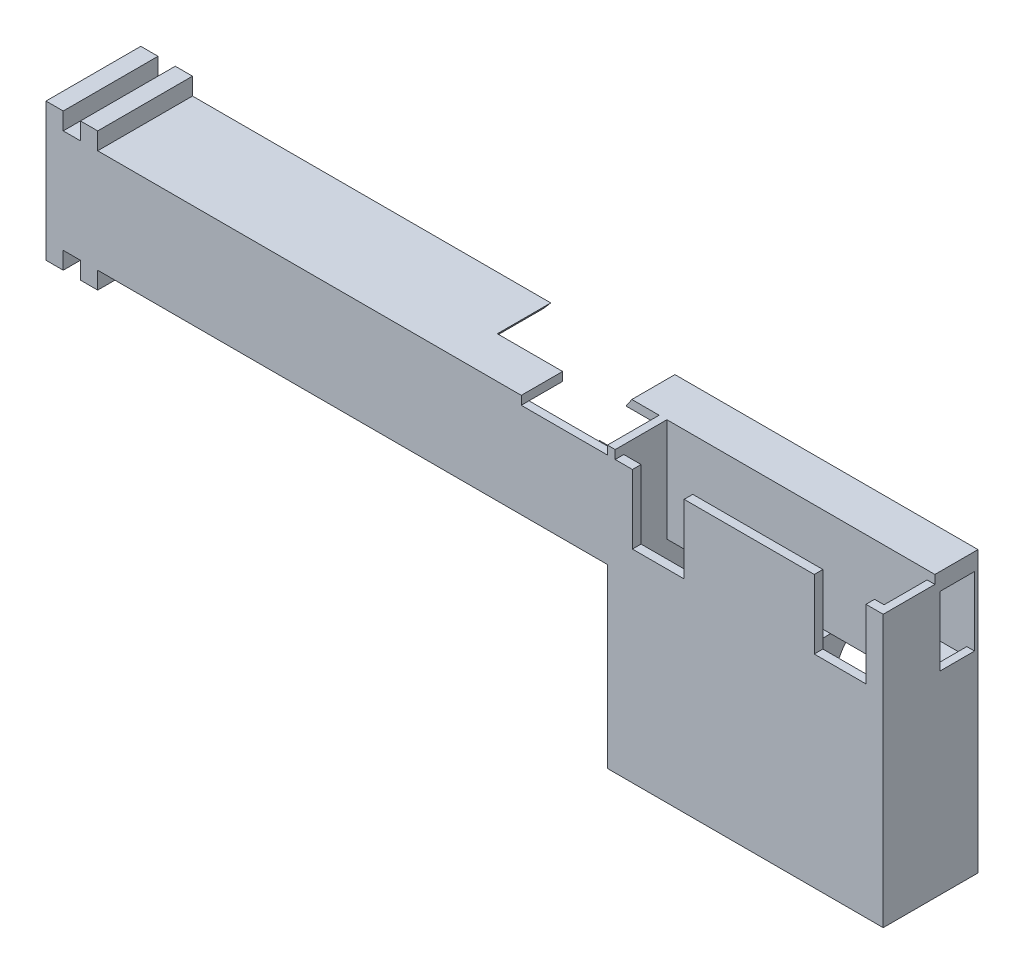
from build123d import *

# Parameters (mm, degrees)
BOSS_EXTRUDE2_DEPTH  = 11
BOSS_EXTRUDE3_DEPTH  = 5
SKETCH2_W            = 30.2
SKETCH2_H            = 1
BOSS_EXTRUDE4_DEPTH  = 25.5
SKETCH1_W            = 7.8
SKETCH1_H            = 14.5
BOSS_EXTRUDE5_DEPTH  = 11
SKETCH3_W            = 11.2
SKETCH3_H            = 11
BOSS_EXTRUDE6_DEPTH  = 5
SKETCH4_W            = 31.1
SKETCH4_H            = 4
CUT_EXTRUDE1_DEPTH   = 10
SKETCH5_W            = 32
SKETCH5_H            = 5
BOSS_EXTRUDE7_DEPTH  = 1
SKETCH7_W            = 5
SKETCH7_H            = 1
SKETCH7_H_2          = 1.003816478
BOSS_EXTRUDE8_DEPTH  = 62.24
SKETCH8_W            = 0.9
SKETCH8_H            = 1
BOSS_EXTRUDE9_DEPTH  = 6
BOSS_EXTRUDE10_DEPTH = 62.26
SKETCH10_W           = 52.24
SKETCH10_H           = 1
BOSS_EXTRUDE11_DEPTH = 6
SKETCH11_R           = 81.7
SKETCH11_R_2         = 70.15
CUT_EXTRUDE2_DEPTH   = 6.2
BOSS_EXTRUDE12_DEPTH = 2.91
SKETCH14_W           = 2
SKETCH14_H           = 11
BOSS_EXTRUDE13_DEPTH = 2
SKETCH15_W           = 2
SKETCH15_H           = 11
BOSS_EXTRUDE14_DEPTH = 2
SKETCH20_RX          = 7.25
SKETCH20_RY          = 5
CUT_EXTRUDE3_DEPTH   = 10
SKETCH21_W           = 6
SKETCH21_H           = 8
CUT_EXTRUDE4_DEPTH   = 1
SKETCH22_W           = 4
SKETCH22_H           = 8
CUT_EXTRUDE5_DEPTH   = 1


with BuildPart() as part:
    # Sketch1_3 → Boss-Extrude2 (new body)
    with BuildSketch(Plane.XY):
        Polygon((0, 31.5), (0, 0), (32, 0), (32, 31.5), (31.1, 31.5), (31.1, 6), (0.9, 6), (0.9, 31.5), align=None)
    extrude(amount=BOSS_EXTRUDE2_DEPTH)

    # Sketch1_4 → Boss-Extrude3 (add)
    with BuildSketch(Plane.XY):
        Polygon((0.9, 31.5), (0.9, 20.5), (12.1, 20.5), (19.9, 20.5), (31.1, 20.5), (31.1, 31.5), align=None)
    extrude(amount=BOSS_EXTRUDE3_DEPTH)

    # Sketch2 → Boss-Extrude4 (add)
    with BuildSketch(Plane(origin=(0, 6, 0), x_dir=(1, 0, 0), z_dir=(0, 1, 0))):
        with Locations((16, -10.5)):
            Rectangle(SKETCH2_W, SKETCH2_H)
    extrude(amount=BOSS_EXTRUDE4_DEPTH)

    # Sketch1 → Boss-Extrude5 (add)
    with BuildSketch(Plane.XY):
        with Locations((16, 13.25)):
            Rectangle(SKETCH1_W, SKETCH1_H)
    extrude(amount=BOSS_EXTRUDE5_DEPTH)

    # Sketch3 → Boss-Extrude6 (add)
    with BuildSketch(Plane(origin=(0, 0, 10), x_dir=(-1, 0, 0), z_dir=(0, 0, -1))):
        with Locations((-6.5, 11.5)):
            Rectangle(SKETCH3_W, SKETCH3_H)
        with Locations((-25.5, 11.5)):
            Rectangle(SKETCH3_W, SKETCH3_H)
    extrude(amount=BOSS_EXTRUDE6_DEPTH)

    # Sketch4 → Cut-Extrude1 (cut)
    with BuildSketch(Plane(origin=(0, 31.5, 0), x_dir=(1, 0, 0), z_dir=(0, 1, 0))):
        with Locations((15.55, -2.4)):
            Rectangle(SKETCH4_W, SKETCH4_H)
    extrude(amount=-CUT_EXTRUDE1_DEPTH, mode=Mode.SUBTRACT)

    # Sketch5 → Boss-Extrude7 (add)
    with BuildSketch(Plane(origin=(0, 31.5, 0), x_dir=(1, 0, 0), z_dir=(0, 1, 0))):
        with Locations((16, -2.5)):
            Rectangle(SKETCH5_W, SKETCH5_H)
    extrude(amount=BOSS_EXTRUDE7_DEPTH)

    # Sketch7 → Boss-Extrude8 (add)
    with BuildSketch(Plane.ZY):
        with Locations((2.5, 32)):
            Rectangle(SKETCH7_W, SKETCH7_H)
        with Locations((2.5, 20.998091761)):
            Rectangle(SKETCH7_W, SKETCH7_H_2)
    extrude(amount=BOSS_EXTRUDE8_DEPTH)

    # Sketch8 → Boss-Extrude9 (add)
    with BuildSketch(Plane.XY.offset(5)):
        with Locations((0.45, 32)):
            Rectangle(SKETCH8_W, SKETCH8_H)
    extrude(amount=BOSS_EXTRUDE9_DEPTH)

    # Sketch9 → Boss-Extrude10 (add)
    with BuildSketch(Plane.ZY):
        Polygon((11, 31.5), (10.1, 31.5), (10.1, 21.499511858), (5, 21.499511858), (5, 20.496183522), (11, 20.496183522), align=None)
    extrude(amount=BOSS_EXTRUDE10_DEPTH)

    # Sketch10 → Boss-Extrude11 (add)
    with BuildSketch(Plane.XY.offset(5)):
        with Locations((-36.12, 32)):
            Rectangle(SKETCH10_W, SKETCH10_H)
    extrude(amount=BOSS_EXTRUDE11_DEPTH)

    # Sketch11 → Cut-Extrude2 (cut)
    with BuildSketch(Plane(origin=(0, 0, 0), x_dir=(-1, 0, 0), z_dir=(0, 0, -1))):
        with Locations((71.241875, 77.677250508)):
            Circle(SKETCH11_R)
        with Locations((71.241875, 77.677250508)):
            Circle(SKETCH11_R_2, mode=Mode.SUBTRACT)
    extrude(amount=-CUT_EXTRUDE2_DEPTH, mode=Mode.SUBTRACT)

    # Sketch12 → Boss-Extrude12 (add)
    with BuildSketch(Plane.ZY.offset(62.24)):
        Polygon((11, 32.5), (0, 32.5), (0, 31.5), (10.1, 31.5), (10.1, 21.5), (0, 21.5), (0, 20.496183522), (11, 20.496183522), align=None)
    extrude(amount=BOSS_EXTRUDE12_DEPTH)

    # Sketch14 → Boss-Extrude13 (add)
    with BuildSketch(Plane(origin=(0, 20.496183522, 0), x_dir=(-1, 0, 0), z_dir=(0, -1, 0))):
        with Locations((64.15, -5.5)):
            Rectangle(SKETCH14_W, SKETCH14_H)
        with Locations((60.15, -5.5)):
            Rectangle(SKETCH14_W, SKETCH14_H)
    extrude(amount=BOSS_EXTRUDE13_DEPTH)

    # Sketch15 → Boss-Extrude14 (add)
    with BuildSketch(Plane(origin=(0, 32.5, 0), x_dir=(1, 0, 0), z_dir=(0, 1, 0))):
        with Locations((-64.15, -5.5)):
            Rectangle(SKETCH15_W, SKETCH15_H)
        with Locations((-60.15, -5.5)):
            Rectangle(SKETCH15_W, SKETCH15_H)
    extrude(amount=BOSS_EXTRUDE14_DEPTH)

    # Sketch20 → Cut-Extrude3 (cut)
    with BuildSketch(Plane(origin=(19.9, 0, 0), x_dir=(0, 0, -1), z_dir=(1, 0, 0))):
        with Locations(Location((0, 13.25), (0, 0, -90))):
            Ellipse(SKETCH20_RX, SKETCH20_RY)
    extrude(amount=-CUT_EXTRUDE3_DEPTH, mode=Mode.SUBTRACT)

    # Sketch21 → Cut-Extrude4 (cut)
    with BuildSketch(Plane.XY.offset(11)):
        with Locations((5.9, 27.5)):
            Rectangle(SKETCH21_W, SKETCH21_H)
        with Locations((27, 27.5)):
            Rectangle(SKETCH21_W, SKETCH21_H)
    extrude(amount=-CUT_EXTRUDE4_DEPTH, mode=Mode.SUBTRACT)

    # Sketch22 → Cut-Extrude5 (cut)
    with BuildSketch(Plane(origin=(32, 0, 0), x_dir=(0, 0, -1), z_dir=(1, 0, 0))):
        with Locations((-2.4, 26.5)):
            Rectangle(SKETCH22_W, SKETCH22_H)
    extrude(amount=-CUT_EXTRUDE5_DEPTH, mode=Mode.SUBTRACT)


solid = part.part
